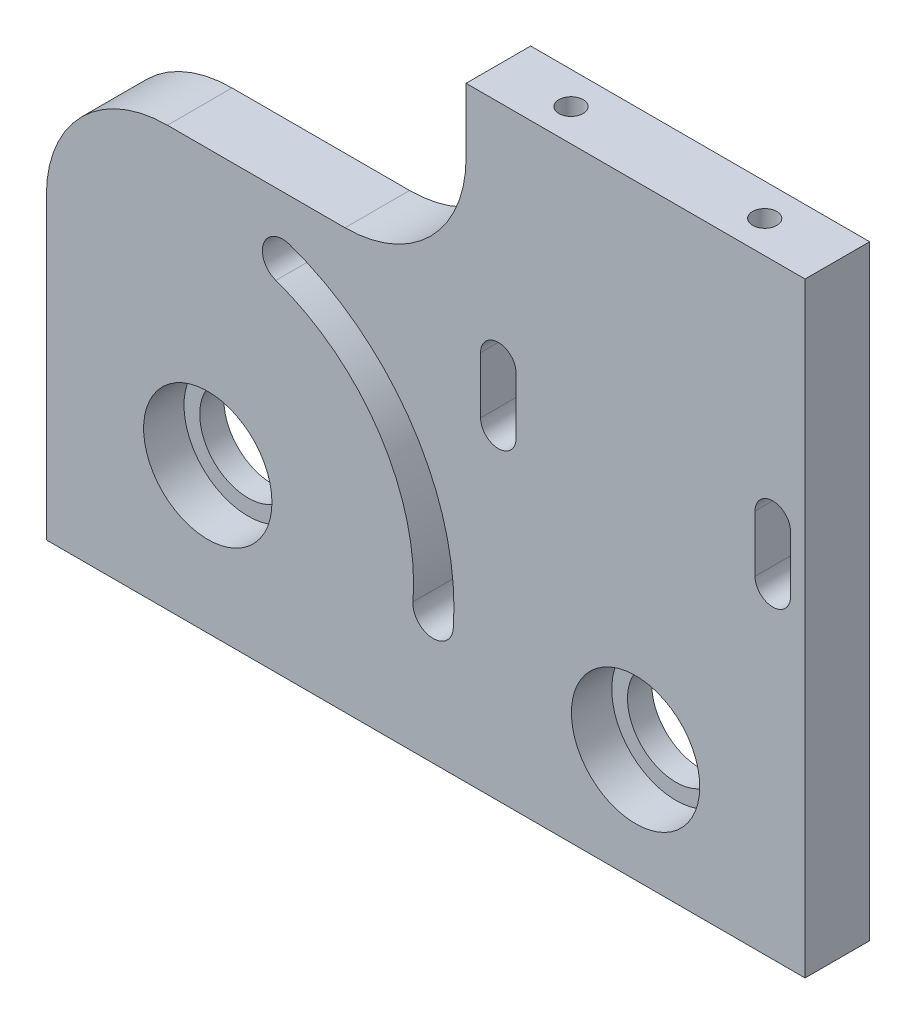
from build123d import *

# Parameters (mm, degrees)
ESQUISSE1_W             = 114.432989691
ESQUISSE1_H             = 75
BOSS_EXTRU_1_DEPTH      = 8
ESQUISSE2_R             = 7.95
ENL_V_MAT_EXTRU_1_DEPTH = 5
ENL_V_MAT_EXTRU_2_REACH = 5
ESQUISSE3_R             = 6
ENL_V_MAT_EXTRU_3_DEPTH = 9
ESQUISSE5_W             = 20.432989691
ESQUISSE5_H             = 75
ENL_V_MAT_EXTRU_4_DEPTH = 9
ENL_V_MAT_EXTRU_5_DEPTH = 9
ESQUISSE7_W             = 52
ESQUISSE7_H             = 23
ENL_V_MAT_EXTRU_6_DEPTH = 9
ESQUISSE10_R            = 1.5
ENL_V_MAT_EXTRU_7_DEPTH = 30
CONG_1_R                = 15
ESQUISSE11_R            = 1.5
ENL_V_MAT_EXTRU_8_DEPTH = 20


with BuildPart() as part:
    # Esquisse1 → Boss.-Extru.1 (new body)
    with BuildSketch(Plane.XY):
        with Locations((57.216494846, 37.5)):
            Rectangle(ESQUISSE1_W, ESQUISSE1_H)
    extrude(amount=BOSS_EXTRU_1_DEPTH)

    # Esquisse2 → Enlèv. mat.-Extru.1 (cut)
    with BuildSketch(Plane.XY.offset(8)):
        with Locations((20, 18)):
            Circle(ESQUISSE2_R)
        with Locations((73, 14)):
            Circle(ESQUISSE2_R)
    extrude(amount=-ENL_V_MAT_EXTRU_1_DEPTH, mode=Mode.SUBTRACT)

    # Esquisse3 → Enlèv. mat.-Extru.2 (cut, up to next)
    with BuildSketch(Plane.XY.offset(3), mode=Mode.PRIVATE) as enl_v_mat_extru_2_sk1:
        with Locations((20, 18)):
            Circle(ESQUISSE3_R)
    enl_v_mat_extru_2_tool1 = extrude(enl_v_mat_extru_2_sk1.sketch, amount=-ENL_V_MAT_EXTRU_2_REACH, mode=Mode.PRIVATE) & part.part
    add(enl_v_mat_extru_2_tool1.solids().sort_by_distance((20, 18, 3))[0], mode=Mode.SUBTRACT)
    # Esquisse3 → Enlèv. mat.-Extru.2 (cut, up to next)
    with BuildSketch(Plane.XY.offset(3), mode=Mode.PRIVATE) as enl_v_mat_extru_2_sk2:
        with Locations((73, 14)):
            Circle(ESQUISSE3_R)
    enl_v_mat_extru_2_tool2 = extrude(enl_v_mat_extru_2_sk2.sketch, amount=-ENL_V_MAT_EXTRU_2_REACH, mode=Mode.PRIVATE) & part.part
    add(enl_v_mat_extru_2_tool2.solids().sort_by_distance((73, 14, 3))[0], mode=Mode.SUBTRACT)

    # Esquisse4 → Enlèv. mat.-Extru.3 (cut, through all)
    with BuildSketch(Plane.XY.offset(8)):
        with BuildLine():
            ThreePointArc((50.413505675, 15.704641081), (45.525982293, 34.69353851), (30.088740957, 46.783107996))
            ThreePointArc((30.088740957, 46.783107996), (26.90252383, 45.250782829), (28.434848997, 42.064565701))
            ThreePointArc((28.434848997, 42.064565701), (41.341395032, 31.956892853), (45.427685072, 16.080929428))
            ThreePointArc((45.427685072, 16.080929428), (47.7324512, 13.399874954), (50.413505675, 15.704641081))
        make_face()
    extrude(amount=-ENL_V_MAT_EXTRU_3_DEPTH, mode=Mode.SUBTRACT)

    # Esquisse5 → Enlèv. mat.-Extru.4 (cut, through all)
    with BuildSketch(Plane.XY.offset(8)):
        with Locations((104.216494845, 37.5)):
            Rectangle(ESQUISSE5_W, ESQUISSE5_H)
    extrude(amount=-ENL_V_MAT_EXTRU_4_DEPTH, mode=Mode.SUBTRACT)

    # Esquisse6 → Enlèv. mat.-Extru.5 (cut, through all)
    with BuildSketch(Plane.XY.offset(8)):
        with BuildLine():
            Line((87.8, 40), (87.8, 47))
            ThreePointArc((87.8, 47), (90, 49.2), (92.2, 47))
            Line((92.2, 47), (92.2, 40))
            ThreePointArc((92.2, 40), (90, 37.8), (87.8, 40))
        make_face()
        with BuildLine():
            Line((58.2, 40), (58.2, 47))
            ThreePointArc((58.2, 47), (56, 49.2), (53.8, 47))
            Line((53.8, 47), (53.8, 40))
            ThreePointArc((53.8, 40), (56, 37.8), (58.2, 40))
        make_face()
    extrude(amount=-ENL_V_MAT_EXTRU_5_DEPTH, mode=Mode.SUBTRACT)

    # Esquisse7 → Enlèv. mat.-Extru.6 (cut, through all)
    with BuildSketch(Plane.XY.offset(8)):
        with Locations((26, 63.5)):
            Rectangle(ESQUISSE7_W, ESQUISSE7_H)
    extrude(amount=-ENL_V_MAT_EXTRU_6_DEPTH, mode=Mode.SUBTRACT)

    # Esquisse10 → Enlèv. mat.-Extru.7 (cut)
    with BuildSketch(Plane(origin=(0, 75, 0), x_dir=(1, 0, 0), z_dir=(0, 1, 0))):
        with Locations((85, -4)):
            Circle(ESQUISSE10_R)
        with Locations((61, -4)):
            Circle(ESQUISSE10_R)
    extrude(amount=-ENL_V_MAT_EXTRU_7_DEPTH, mode=Mode.SUBTRACT)

    # Congé1
    cong_1_edges = [part.edges().sort_by_distance(p)[0] for p in [
        (52, 52, 4),
        (0, 52, 4),
    ]]
    fillet(cong_1_edges, radius=CONG_1_R)

    # Esquisse11 → Enlèv. mat.-Extru.8 (cut)
    with BuildSketch(Plane.XZ):
        with Locations((6, 4)):
            Circle(ESQUISSE11_R)
        with Locations((88, 4)):
            Circle(ESQUISSE11_R)
    extrude(amount=-ENL_V_MAT_EXTRU_8_DEPTH, mode=Mode.SUBTRACT)


solid = part.part
